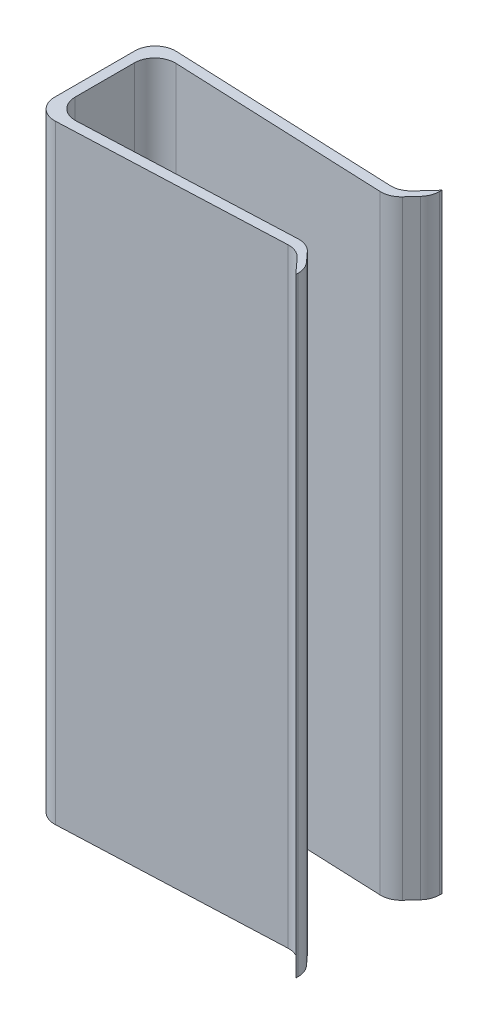
from build123d import *

# Parameters (mm, degrees)
BOSS_EXTRUDE1_DEPTH = 30
FILLET1_R           = 1


with BuildPart() as part:
    # Sketch1 → Boss-Extrude1 (new body)
    with BuildSketch(Plane(origin=(0, 0, 0), x_dir=(1, 0, 0), z_dir=(0, 1, 0))):
        Polygon((-6, -2.5), (-6, 2.5), (6, 2), (7, 3.09567943), (7, 3.59567943), (6, 2.5), (-6.5, 3.020833333), (-6.5, -3.020833333), (6, -2.5), (7, -3.59567943), (7, -3.09567943), (6, -2), align=None)
    extrude(amount=BOSS_EXTRUDE1_DEPTH)

    # Fillet1
    fillet1_edges = [part.edges().sort_by_distance(p)[0] for p in [
        (-6.5, 15, 3.020833333),
        (-6.5, 15, -3.020833333),
        (6, 15, -2.5),
        (7, 15, -3.09567943),
        (6, 15, -2),
        (-6, 15, -2.5),
        (-6, 15, 2.5),
        (6, 15, 2),
        (7, 15, 3.09567943),
        (6, 15, 2.5),
    ]]
    fillet(fillet1_edges, radius=FILLET1_R)


solid = part.part
